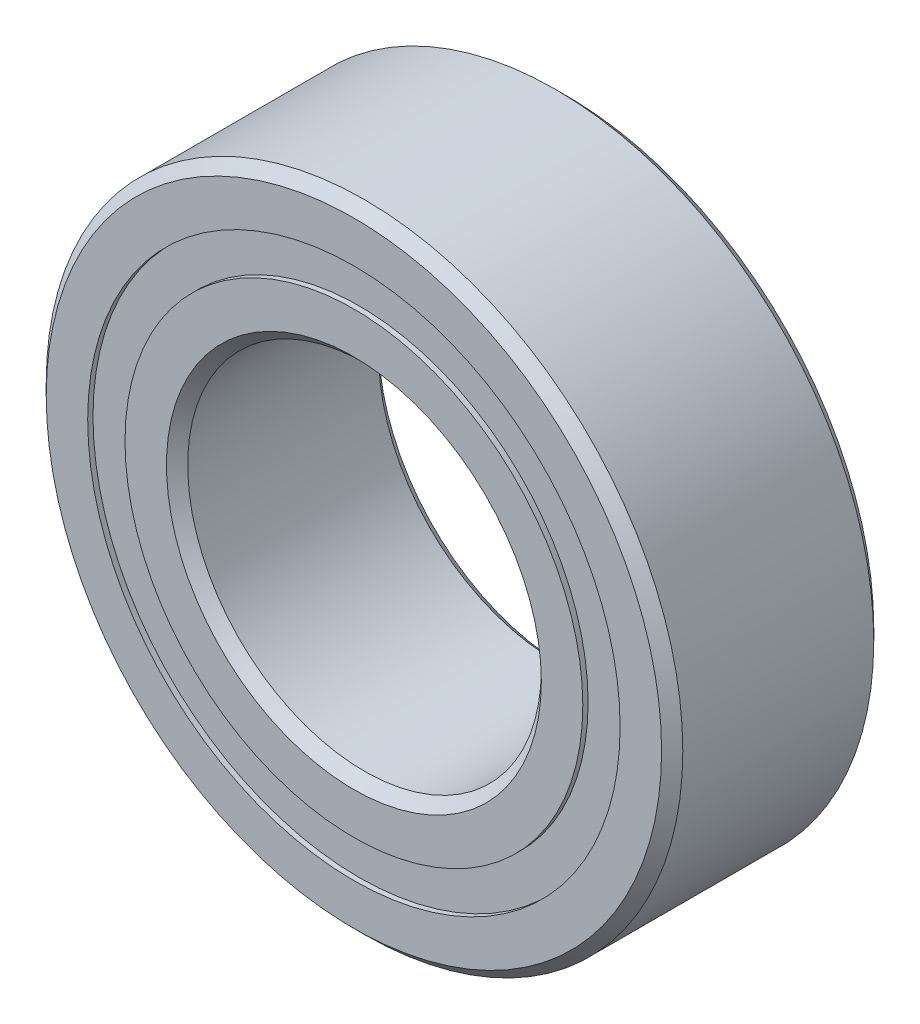
from build123d import *

# Parameters (mm, degrees)
CIRPATTERN1_COUNT = 12
SKETCH5_W         = 0.708061187
SKETCH5_H         = 0.527472528


with BuildPart() as part:
    # Sketch1 → Revolve1 (revolve)
    with BuildSketch(Plane(origin=(0, 0, 0), x_dir=(0, 0, -1), z_dir=(1, 0, 0))):
        with BuildLine():
            Line((1.35, 4.5), (-1.35, 4.5))
            Line((-1.35, 4.5), (-1.5, 4.35))
            Line((-1.5, 4.35), (-1.5, 3.763736264))
            Line((-1.5, 3.763736264), (-0.666666667, 3.763736264))
            ThreePointArc((-0.666666667, 3.763736264), (0, 4.216938813), (0.666666667, 3.763736264))
            Line((0.666666667, 3.763736264), (1.5, 3.763736264))
            Line((1.5, 3.763736264), (1.5, 4.35))
            Line((1.5, 4.35), (1.35, 4.5))
        make_face()
    revolve(axis=Axis((0, 0, 1.5), (0, 0, -1)))


with BuildPart() as body_2:
    # Sketch3 → Revolve3 (revolve)
    with BuildSketch(Plane(origin=(0, 0, 0), x_dir=(0, 0, -1), z_dir=(1, 0, 0))):
        with BuildLine():
            Line((-1.5, 3.236263736), (-0.666666667, 3.236263736))
            ThreePointArc((-0.666666667, 3.236263736), (0, 2.783061187), (0.666666667, 3.236263736))
            Line((0.666666667, 3.236263736), (1.5, 3.236263736))
            Line((1.5, 3.236263736), (1.5, 2.65))
            Line((1.5, 2.65), (1.35, 2.5))
            Line((1.35, 2.5), (-1.35, 2.5))
            Line((-1.35, 2.5), (-1.5, 2.65))
            Line((-1.5, 2.65), (-1.5, 3.236263736))
        make_face()
    revolve(axis=Axis((0, 0, 1.5), (0, 0, -1)))


with BuildPart() as body_3:
    # Sketch4 → Revolve4 (revolve)
    with BuildSketch(Plane(origin=(0, 0, 0), x_dir=(0, 0, -1), z_dir=(1, 0, 0))):
        with BuildLine():
            Line((-0.716938813, 3.5), (0.716938813, 3.5))
            ThreePointArc((0.716938813, 3.5), (0, 4.216938813), (-0.716938813, 3.5))
        make_face()
    revolve(axis=Axis((0, 3.5, 0.716938813), (0, 0, -1)))


with BuildPart() as cirpattern1_1:
    # CirPattern1: pattern copy
    add(body_3.part.rotate(Axis((0, 0, 0), (0, 0, 1)), 1 * 360 / CIRPATTERN1_COUNT))


with BuildPart() as cirpattern1_2:
    # CirPattern1: pattern copy
    add(body_3.part.rotate(Axis((0, 0, 0), (0, 0, 1)), 2 * 360 / CIRPATTERN1_COUNT))


with BuildPart() as cirpattern1_3:
    # CirPattern1: pattern copy
    add(body_3.part.rotate(Axis((0, 0, 0), (0, 0, 1)), 3 * 360 / CIRPATTERN1_COUNT))


with BuildPart() as cirpattern1_4:
    # CirPattern1: pattern copy
    add(body_3.part.rotate(Axis((0, 0, 0), (0, 0, 1)), 4 * 360 / CIRPATTERN1_COUNT))


with BuildPart() as cirpattern1_5:
    # CirPattern1: pattern copy
    add(body_3.part.rotate(Axis((0, 0, 0), (0, 0, 1)), 5 * 360 / CIRPATTERN1_COUNT))


with BuildPart() as cirpattern1_6:
    # CirPattern1: pattern copy
    add(body_3.part.rotate(Axis((0, 0, 0), (0, 0, 1)), 6 * 360 / CIRPATTERN1_COUNT))


with BuildPart() as cirpattern1_7:
    # CirPattern1: pattern copy
    add(body_3.part.rotate(Axis((0, 0, 0), (0, 0, 1)), 7 * 360 / CIRPATTERN1_COUNT))


with BuildPart() as cirpattern1_8:
    # CirPattern1: pattern copy
    add(body_3.part.rotate(Axis((0, 0, 0), (0, 0, 1)), 8 * 360 / CIRPATTERN1_COUNT))


with BuildPart() as cirpattern1_9:
    # CirPattern1: pattern copy
    add(body_3.part.rotate(Axis((0, 0, 0), (0, 0, 1)), 9 * 360 / CIRPATTERN1_COUNT))


with BuildPart() as cirpattern1_10:
    # CirPattern1: pattern copy
    add(body_3.part.rotate(Axis((0, 0, 0), (0, 0, 1)), 10 * 360 / CIRPATTERN1_COUNT))


with BuildPart() as cirpattern1_11:
    # CirPattern1: pattern copy
    add(body_3.part.rotate(Axis((0, 0, 0), (0, 0, 1)), 11 * 360 / CIRPATTERN1_COUNT))


with BuildPart() as body_15:
    # Sketch5 → Revolve5 (revolve)
    with BuildSketch(Plane(origin=(0, 0, 0), x_dir=(0, 0, -1), z_dir=(1, 0, 0))):
        with Locations((-1.070969407, 3.5)):
            Rectangle(SKETCH5_W, SKETCH5_H)
        with Locations((1.070969407, 3.5)):
            Rectangle(SKETCH5_W, SKETCH5_H)
    revolve(axis=Axis((0, 0, 1.5), (0, 0, -1)))


solid = Compound([part.part, body_2.part, body_3.part, cirpattern1_1.part, cirpattern1_2.part, cirpattern1_3.part, cirpattern1_4.part, cirpattern1_5.part, cirpattern1_6.part, cirpattern1_7.part, cirpattern1_8.part, cirpattern1_9.part, cirpattern1_10.part, cirpattern1_11.part, body_15.part])
